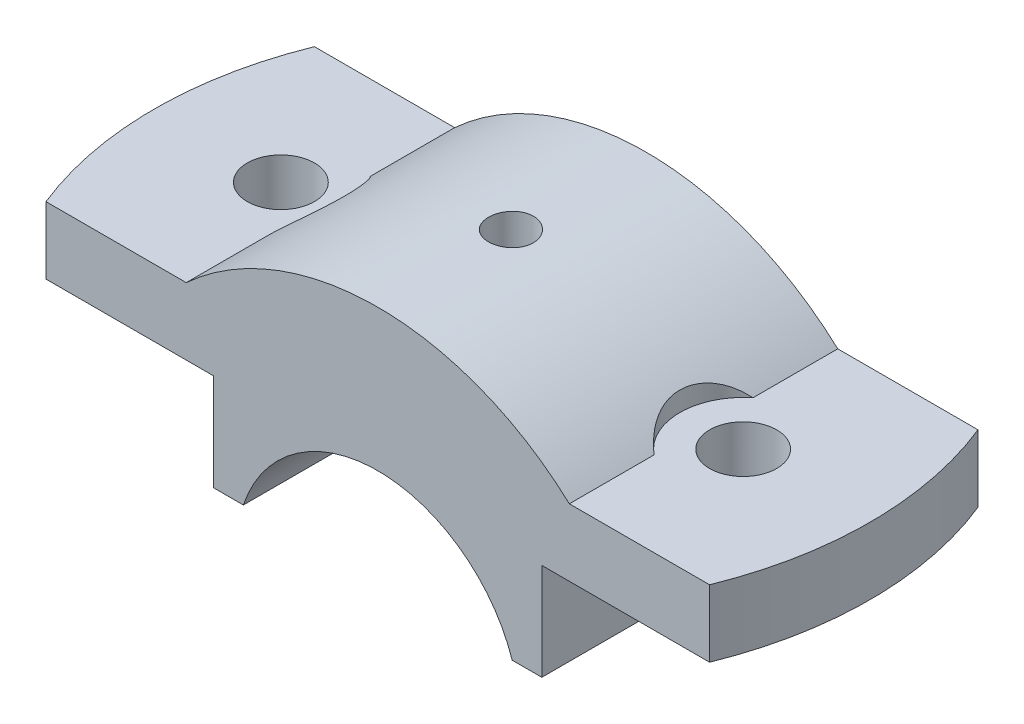
from build123d import *

# Parameters (mm, degrees)
BOSS_EXTRUDE1_DEPTH   = 18
F_6_0MM_DOWEL_HOLE2_D = 9
SKETCH24_R            = 8.5
CUT_EXTRUDE7_DEPTH    = 19
CUT_EXTRUDE8_DEPTH    = 23
F_6_0MM_DOWEL_HOLE3_D = 9


with BuildPart() as part:
    # Sketch1 → Boss-Extrude1 (new body, symmetric)
    with BuildSketch(Plane.XY):
        with BuildLine():
            Line((-18.027756377, 6), (-22, 6))
            Line((-22, 6), (-22, 19))
            Line((-22, 19), (-50, 19))
            Line((-50, 19), (-50, 28))
            Line((-50, 28), (-25.690465157, 28))
            ThreePointArc((-25.690465157, 28), (-13.784048752, 35.411862419), (0, 38))
            Line((0, 38), (0, 19))
            ThreePointArc((0, 19), (-11.113055385, 15.411035007), (-18.027756377, 6))
        make_face()
    boss_extrude1 = extrude(amount=BOSS_EXTRUDE1_DEPTH, both=True)

    # Mirror1: Boss-Extrude1 across plane
    add(boss_extrude1.mirror(Plane(origin=(0, 0, 0), x_dir=(0, 0, 1), z_dir=(1, 0, 0))))

    # Ø6.0mm Dowel Hole2 (through all)
    with Locations(Plane(origin=(0, 28, 0), x_dir=(1, 0, 0), z_dir=(0, 1, 0))):
        with Locations((-31, 0)):
            Hole(F_6_0MM_DOWEL_HOLE2_D / 2)

    # Sketch24 → Cut-Extrude7 (cut)
    with BuildSketch(Plane(origin=(0, 28, 0), x_dir=(1, 0, 0), z_dir=(0, 1, 0))):
        with Locations((-31, 0)):
            Circle(SKETCH24_R)
    cut_extrude7 = extrude(amount=CUT_EXTRUDE7_DEPTH, mode=Mode.SUBTRACT)

    # Mirror5: Cut-Extrude7 across plane
    add(cut_extrude7.mirror(Plane(origin=(0, 0, 0), x_dir=(0, 0, 1), z_dir=(1, 0, 0))), mode=Mode.SUBTRACT)

    # Sketch25 → Cut-Extrude8 (cut, through all)
    with BuildSketch(Plane(origin=(0, 28, 0), x_dir=(1, 0, 0), z_dir=(0, 1, 0))):
        with BuildLine():
            Line((-44.497190923, 18), (-50, 18))
            Line((-50, 18), (-50, -18))
            Line((-50, -18), (-44.497190923, -18))
            ThreePointArc((-44.497190923, -18), (-48, 0), (-44.497190923, 18))
        make_face()
    cut_extrude8 = extrude(amount=-CUT_EXTRUDE8_DEPTH, mode=Mode.SUBTRACT)

    # Mirror7: Cut-Extrude8 across plane
    add(cut_extrude8.mirror(Plane(origin=(0, 0, 0), x_dir=(0, 0, 1), z_dir=(1, 0, 0))), mode=Mode.SUBTRACT)

    # Sketch28 → CBORE for M6 Hex Head Machine Screw1 (revolve, cut)
    with BuildSketch(Plane(origin=(-0.146360812, 37.999718137, 0), x_dir=(-0.999992583, -0.0038516, 0), z_dir=(0, 0, 1))):
        Polygon((0, 0), (0, 32.18492132), (2.5, 32.18492132), (2.5, 13.825), (3.325, 13), (3, 13), (3, 0), align=None)
    revolve(axis=Axis((-0.170818474, 44.349671037, 0), (0.0038516, -0.999992583, 0)), mode=Mode.SUBTRACT)

    # Ø6.0mm Dowel Hole3 (through all)
    with Locations(Plane(origin=(0, 28, 0), x_dir=(1, 0, 0), z_dir=(0, 1, 0))):
        with Locations((31, 0)):
            Hole(F_6_0MM_DOWEL_HOLE3_D / 2)


solid = part.part
